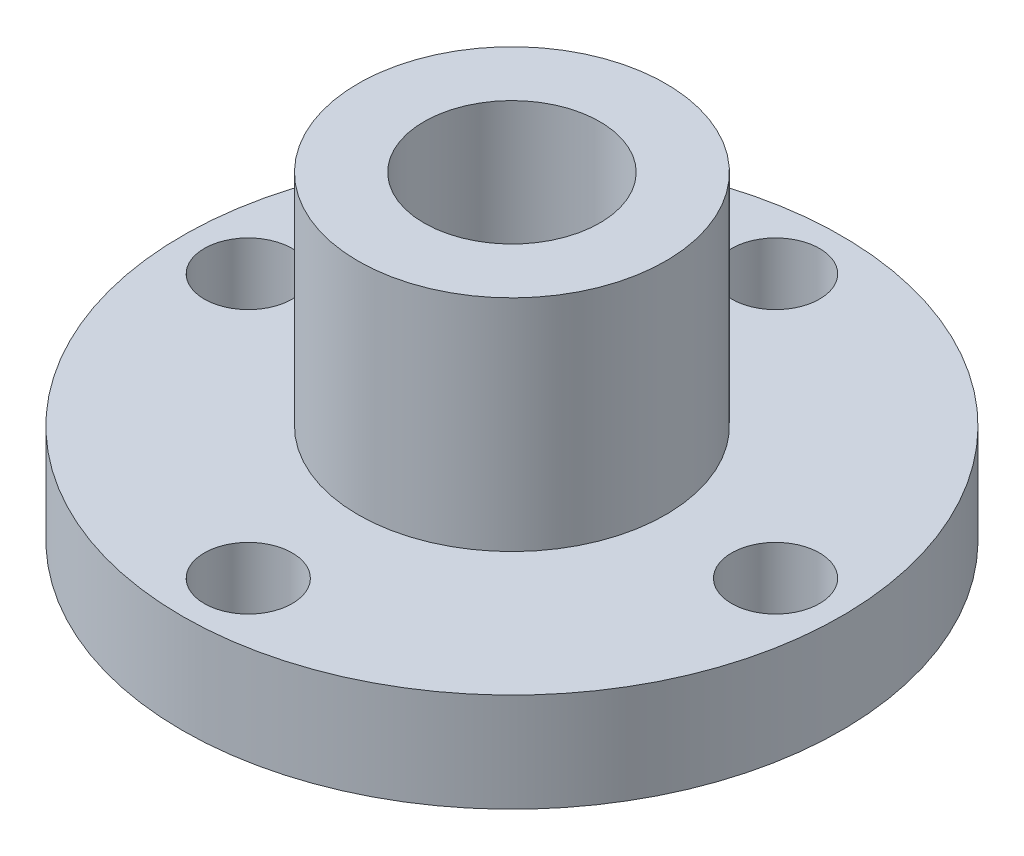
from build123d import *

# Parameters (mm, degrees)
SKETCH1_R           = 15
BOSS_EXTRUDE1_DEPTH = 4.5
SKETCH3_R           = 7
BOSS_EXTRUDE2_DEPTH = 10
SKETCH4_R           = 4
CUT_EXTRUDE1_DEPTH  = 15
SKETCH5_R           = 2
CUT_EXTRUDE2_DEPTH  = 10


with BuildPart() as part:
    # Sketch1 → Boss-Extrude1 (new body)
    with BuildSketch(Plane(origin=(0, 0, 0), x_dir=(1, 0, 0), z_dir=(0, 1, 0))):
        Circle(SKETCH1_R)
    extrude(amount=BOSS_EXTRUDE1_DEPTH)

    # Sketch3 → Boss-Extrude2 (add)
    with BuildSketch(Plane(origin=(0, 4.5, 0), x_dir=(1, 0, 0), z_dir=(0, 1, 0))):
        Circle(SKETCH3_R)
    extrude(amount=BOSS_EXTRUDE2_DEPTH)

    # Sketch4 → Cut-Extrude1 (cut)
    with BuildSketch(Plane(origin=(0, 14.5, 0), x_dir=(1, 0, 0), z_dir=(0, 1, 0))):
        Circle(SKETCH4_R)
    extrude(amount=-CUT_EXTRUDE1_DEPTH, mode=Mode.SUBTRACT)

    # Sketch5 → Cut-Extrude2 (cut)
    with BuildSketch(Plane(origin=(0, 4.5, 0), x_dir=(1, 0, 0), z_dir=(0, 1, 0))):
        with Locations((0, 12)):
            Circle(SKETCH5_R)
        with Locations((12, 0)):
            Circle(SKETCH5_R)
        with Locations((0, -12)):
            Circle(SKETCH5_R)
        with Locations((-12, 0)):
            Circle(SKETCH5_R)
    extrude(amount=-CUT_EXTRUDE2_DEPTH, mode=Mode.SUBTRACT)


solid = part.part
